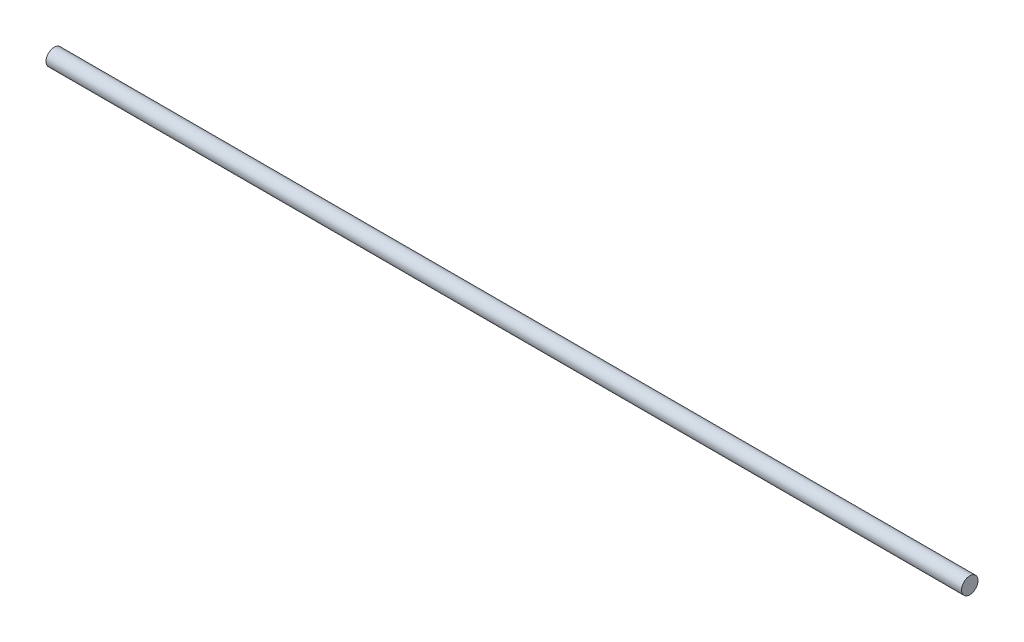
from build123d import *

# Parameters (mm, degrees)
SKETCH1_W = 167
SKETCH1_H = 1.5


with BuildPart() as part:
    # Sketch1 → Revolve1 (revolve)
    with BuildSketch(Plane.XY):
        with Locations((83.5, -0.75)):
            Rectangle(SKETCH1_W, SKETCH1_H)
    revolve(axis=Axis((0, 0, 0), (1, 0, 0)))


solid = part.part
